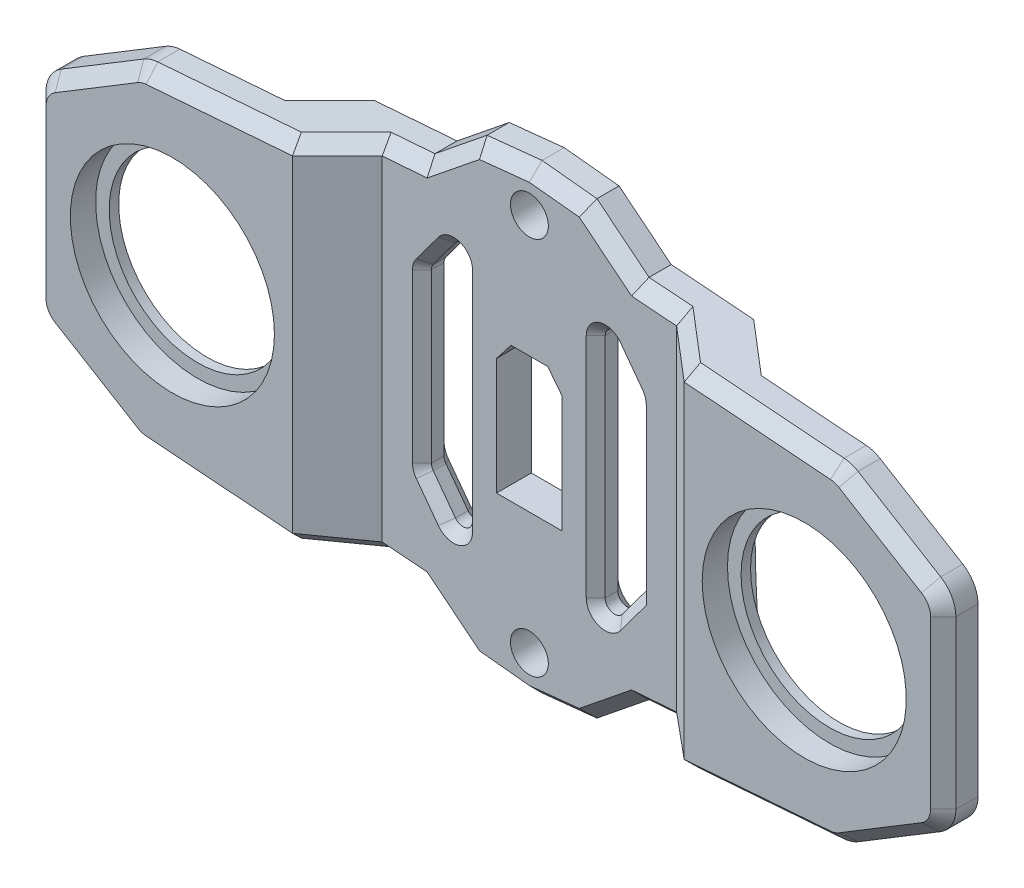
from build123d import *
from OCP.BRepFilletAPI import BRepFilletAPI_MakeChamfer

# Parameters (mm, degrees)
SKETCH1_R               = 3
SKETCH1_R_2             = 16.15
BOSS_EXTRUDE1_DEPTH     = 12
CUT_EXTRUDE1_DEPTH      = 82.610354735
CUT_EXTRUDE1_DEPTH_BACK = 82.610354735
CUT_EXTRUDE2_DEPTH      = 81.984566431
CUT_EXTRUDE2_DEPTH_BACK = 81.984566431
CUT_EXTRUDE3_DEPTH      = 81.984566431
CUT_EXTRUDE3_DEPTH_BACK = 81.984566431
FILLET1_R               = 1.5
SKETCH5_R               = 18.073165259
SKETCH5_R_2             = 14
BOSS_EXTRUDE2_DEPTH     = 1.5
FILLET2_R               = 5
CHAMFER1_SIZE           = 2
CHAMFER1_SIZE2          = 1.908627476
SKETCH7_R               = 18.5
CUT_EXTRUDE4_DEPTH      = 81.984566431
CHAMFER2_SIZE           = 2
CHAMFER3_SIZE           = 1.5


with BuildPart() as part:
    # Sketch1 → Boss-Extrude1 (new body)
    with BuildSketch(Plane.XY):
        Polygon((-72, 16), (-72, -16), (-55.5, -26), (-16.944232072, -28.942026003), (-8.689847933, -35.598787405), (0, -36.5), (8.689847933, -35.598787405), (16.944232072, -28.942026003), (55.5, -26), (72, -16), (72, 16), (55.5, 26), (16.944232072, 28.942026003), (8.689847933, 35.598787405), (0, 36.5), (-8.689847933, 35.598787405), (-16.944232072, 28.942026003), (-55.5, 26), align=None)
        with Locations((0, 30)):
            Circle(SKETCH1_R, mode=Mode.SUBTRACT)
        with Locations((-50, 0)):
            Circle(SKETCH1_R_2, mode=Mode.SUBTRACT)
        with Locations(Location((0, -30, 0), (0, 0, 180))):
            Circle(SKETCH1_R, mode=Mode.SUBTRACT)
        with Locations(Location((50, 0, 0), (0, 0, 180))):
            Circle(SKETCH1_R_2, mode=Mode.SUBTRACT)
    extrude(amount=BOSS_EXTRUDE1_DEPTH)

    # Sketch2 → Cut-Extrude1 (cut, two sides)
    with BuildSketch(Plane(origin=(0, 0, 0), x_dir=(1, 0, 0), z_dir=(0, 1, 0))) as cut_extrude1_sk:
        Polygon((-31, -12), (-23.3, -5.5), (4.394576276, -5.5), (23.3, -5.5), (31, -12), align=None)
        Polygon((-72, 0), (-72, -6.5), (-37.7, -6.5), (-30, 0), align=None)
        Polygon((30, 0), (72, 0), (72, -6.5), (37.7, -6.5), align=None)
    extrude(amount=CUT_EXTRUDE1_DEPTH, mode=Mode.SUBTRACT)
    extrude(cut_extrude1_sk.sketch, amount=-CUT_EXTRUDE1_DEPTH_BACK, mode=Mode.SUBTRACT)

    # Sketch3 → Cut-Extrude2 (cut, two sides)
    with BuildSketch(Plane.XY.offset(5.5)) as cut_extrude2_sk:
        Polygon((5.2, -10.7), (-5.2, -10.7), (-5.2, 7.758003241), (-2.908652734, 10.7), (2.908652734, 10.7), (5.2, 7.758003241), align=None)
    extrude(amount=CUT_EXTRUDE2_DEPTH, mode=Mode.SUBTRACT)
    extrude(cut_extrude2_sk.sketch, amount=-CUT_EXTRUDE2_DEPTH_BACK, mode=Mode.SUBTRACT)

    # Sketch4 → Cut-Extrude3 (cut, two sides)
    with BuildSketch(Plane.XY.offset(5.5)) as cut_extrude3_sk:
        Polygon((-17, 13.75), (-17, -13.75), (-10.5, -22.5), (-10.5, 22.5), align=None)
        Polygon((17, 13.75), (10.5, 22.5), (10.5, -22.5), (17, -13.75), align=None)
    extrude(amount=CUT_EXTRUDE3_DEPTH, mode=Mode.SUBTRACT)
    extrude(cut_extrude3_sk.sketch, amount=-CUT_EXTRUDE3_DEPTH_BACK, mode=Mode.SUBTRACT)

    # Fillet1
    fillet1_edges = [part.edges().sort_by_distance(p)[0] for p in [
        (-10.5, -22.5, 2.75),
        (-17, -13.75, 2.75),
        (-17, 13.75, 2.75),
        (-10.5, 22.5, 2.75),
        (17, 13.75, 2.75),
        (10.5, -22.5, 2.75),
        (10.5, 22.5, 2.75),
    ]]
    fillet(fillet1_edges, radius=FILLET1_R)

    # Sketch5 → Boss-Extrude2 (add)
    with BuildSketch(Plane.XY.offset(6.5)):
        with Locations((-50, 0)):
            Circle(SKETCH5_R)
        with Locations((-50, 0)):
            Circle(SKETCH5_R_2, mode=Mode.SUBTRACT)
        with Locations((50, 0)):
            Circle(SKETCH5_R)
        with Locations(Location((50, 0, 0), (0, 0, 180))):
            Circle(SKETCH5_R_2, mode=Mode.SUBTRACT)
    extrude(amount=BOSS_EXTRUDE2_DEPTH)

    # Fillet2
    fillet2_edges = [part.edges().sort_by_distance(p)[0] for p in [
        (55.5, 26, 9.25),
        (72, 16, 9.25),
        (72, -16, 9.25),
        (55.5, -26, 9.25),
        (-55.5, -26, 9.25),
        (-72, -16, 9.25),
        (-72, 16, 9.25),
        (-55.5, 26, 9.25),
    ]]
    fillet(fillet2_edges, radius=FILLET2_R)

    # Chamfer1: one chamfer whose edges measure the first distance from different faces: ONE call of the kernel's chamfer builder (chamfer() names one face for all edges)
    chamfer1_edges_1 = [part.edges().sort_by_distance(p)[0] for p in [
        (-27.15, 28.163267435, 8.75),
        (-27.15, -28.163267435, 8.75),
    ]]
    chamfer1_side_1 = [part.faces().sort_by_distance(p)[0] for p in [
        (-27.136613276, 0, 8.738699519),
    ]]
    chamfer1_edges_2 = [part.edges().sort_by_distance(p)[0] for p in [
        (27.15, -28.163267435, 8.75),
        (27.15, 28.163267435, 8.75),
    ]]
    chamfer1_side_2 = [part.faces().sort_by_distance(p)[0] for p in [
        (27.136613276, 0, 8.738699519),
    ]]
    chamfer1_edges_3 = [part.edges().sort_by_distance(p)[0] for p in [
        (-12.817040003, -32.270406704, 5.5),
        (-20.122116036, -28.699535248, 5.5),
        (-20.122116036, 28.699535248, 5.5),
        (-12.817040003, 32.270406704, 5.5),
        (-4.344923967, 36.049393703, 5.5),
        (4.344923967, 36.049393703, 5.5),
        (12.817040003, 32.270406704, 5.5),
        (20.122116036, 28.699535248, 5.5),
        (20.122116036, -28.699535248, 5.5),
        (12.817040003, -32.270406704, 5.5),
        (4.344923967, -36.049393703, 5.5),
        (-4.344923967, -36.049393703, 5.5),
        (42.654881047, 26.980156174, 12),
        (63.056178259, 21.420498025, 12),
        (63.056178259, -21.420498025, 12),
        (72, 0, 12),
        (71.356463181, 15.637521788, 12),
        (71.356463181, -15.637521788, 12),
        (55.457065699, -25.866202879, 12),
        (55.457065699, 25.866202879, 12),
        (-42.654881047, -26.980156174, 12),
        (-63.056178259, -21.420498025, 12),
        (-63.056178259, 21.420498025, 12),
        (-72, 0, 12),
        (-71.356463181, 15.637521788, 12),
        (-71.356463181, -15.637521788, 12),
        (-55.457065699, 25.866202879, 12),
        (-55.457065699, -25.866202879, 12),
        (42.654881047, -26.980156174, 12),
        (-42.654881047, 26.980156174, 12),
    ]]
    chamfer1 = BRepFilletAPI_MakeChamfer(part.part.solid().wrapped)
    for e in chamfer1_edges_1:
        chamfer1.Add(CHAMFER1_SIZE, CHAMFER1_SIZE2, e.wrapped, chamfer1_side_1[0].wrapped)  # the first distance lies on this face
    for e in chamfer1_edges_2:
        chamfer1.Add(CHAMFER1_SIZE, CHAMFER1_SIZE2, e.wrapped, chamfer1_side_2[0].wrapped)  # the first distance lies on this face
    for e in chamfer1_edges_3:
        chamfer1.Add(CHAMFER1_SIZE, e.wrapped)
    add(Compound.cast(chamfer1.Shape()), mode=Mode.REPLACE)

    # Sketch7 → Cut-Extrude4 (cut, through all)
    with BuildSketch(Plane(origin=(0, 0, 6.5), x_dir=(-1, 0, 0), z_dir=(0, 0, -1))):
        with Locations((-50, 0)):
            Circle(SKETCH7_R)
        with Locations((50, 0)):
            Circle(SKETCH7_R)
    extrude(amount=CUT_EXTRUDE4_DEPTH, mode=Mode.SUBTRACT)

    # Chamfer2
    chamfer2_edges = [part.edges().sort_by_distance(p)[0] for p in [
        (17, -0.248090155, 0),
        (14.954115772, 16.504074922, 0),
        (10.5, 0, 0),
        (15.102057886, -16.304922077, 0),
        (-10.5, 0, 0),
        (-14.954115772, -16.504074922, 0),
        (-17, 0, 0),
        (-14.954115772, 16.504074922, 0),
        (16.924109135, 13.724896298, 0),
        (11.528923392, 19.389467286, 0),
        (11.528923392, -19.389467286, 0),
        (-11.528923392, -19.389467286, 0),
        (-16.924109135, -13.724896298, 0),
        (-16.924109135, 13.724896298, 0),
        (-11.528923392, 19.389467286, 0),
    ]]
    chamfer(chamfer2_edges, length=CHAMFER2_SIZE)

    # Chamfer3
    chamfer3_edges = [part.edges().sort_by_distance(p)[0] for p in [
        (15.102057886, -16.304922077, 5.5),
        (14.954115772, 16.504074922, 5.5),
        (17, -0.248090155, 5.5),
        (10.5, 0, 5.5),
        (-10.5, 0, 5.5),
        (-14.954115772, -16.504074922, 5.5),
        (-17, 0, 5.5),
        (-14.954115772, 16.504074922, 5.5),
        (16.924109135, 13.724896298, 5.5),
        (11.528923392, 19.389467286, 5.5),
        (11.528923392, -19.389467286, 5.5),
        (-11.528923392, -19.389467286, 5.5),
        (-16.924109135, -13.724896298, 5.5),
        (-16.924109135, 13.724896298, 5.5),
        (-11.528923392, 19.389467286, 5.5),
    ]]
    chamfer(chamfer3_edges, length=CHAMFER3_SIZE)


solid = part.part
